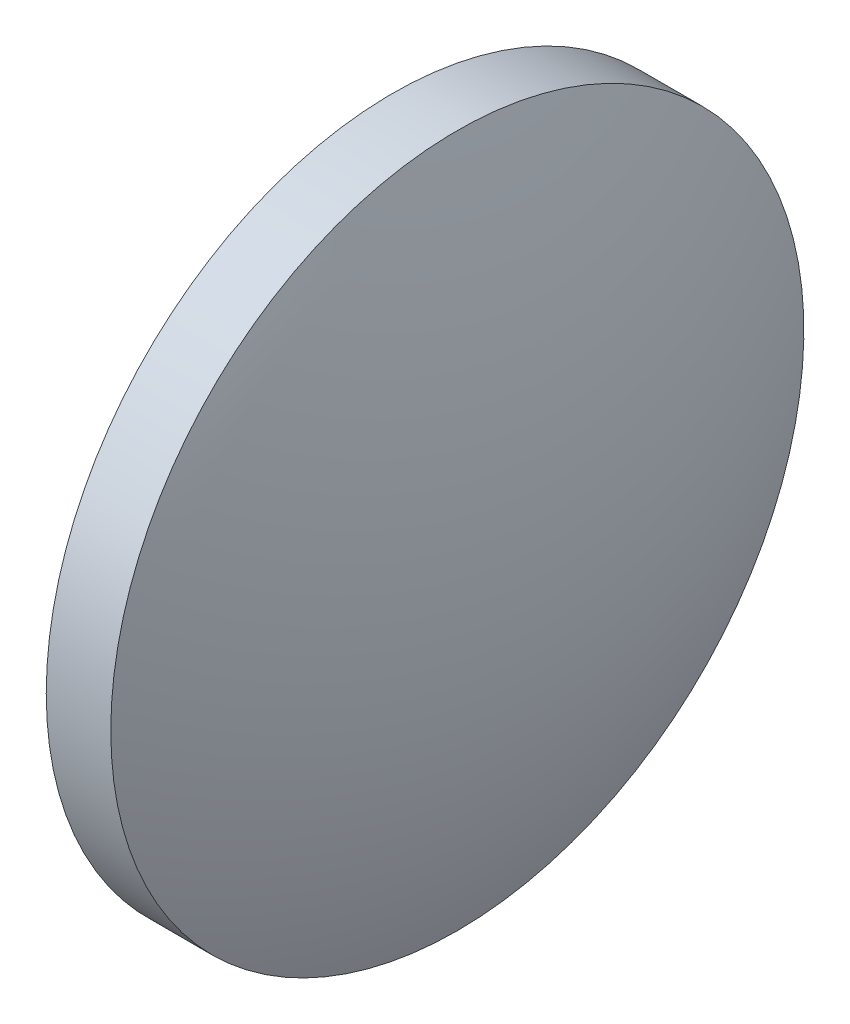
from build123d import *


with BuildPart() as part:
    # 草图1 → 旋转1 (revolve)
    with BuildSketch(Plane.XY, mode=Mode.PRIVATE) as revolve_1_sk:
        with BuildLine():
            Line((536.647209636, 122.083366166), (536.647209636, 130.083366166))
            Line((536.647209636, 130.083366166), (538.137209636, 130.083366166))
            ThreePointArc((538.137209636, 130.083366166), (539.340714667, 126.163565303), (539.747209636, 122.083366166))
            Line((539.747209636, 122.083366166), (536.647209636, 122.083366166))
        make_face()
    revolve(revolve_1_sk.sketch.rotate(Axis((534.724392932, 122.083366166, 0), (1, 0, 0)), 180), axis=Axis((534.724392932, 122.083366166, 0), (1, 0, 0)))  # turned: the seam where the file's is


solid = part.part
